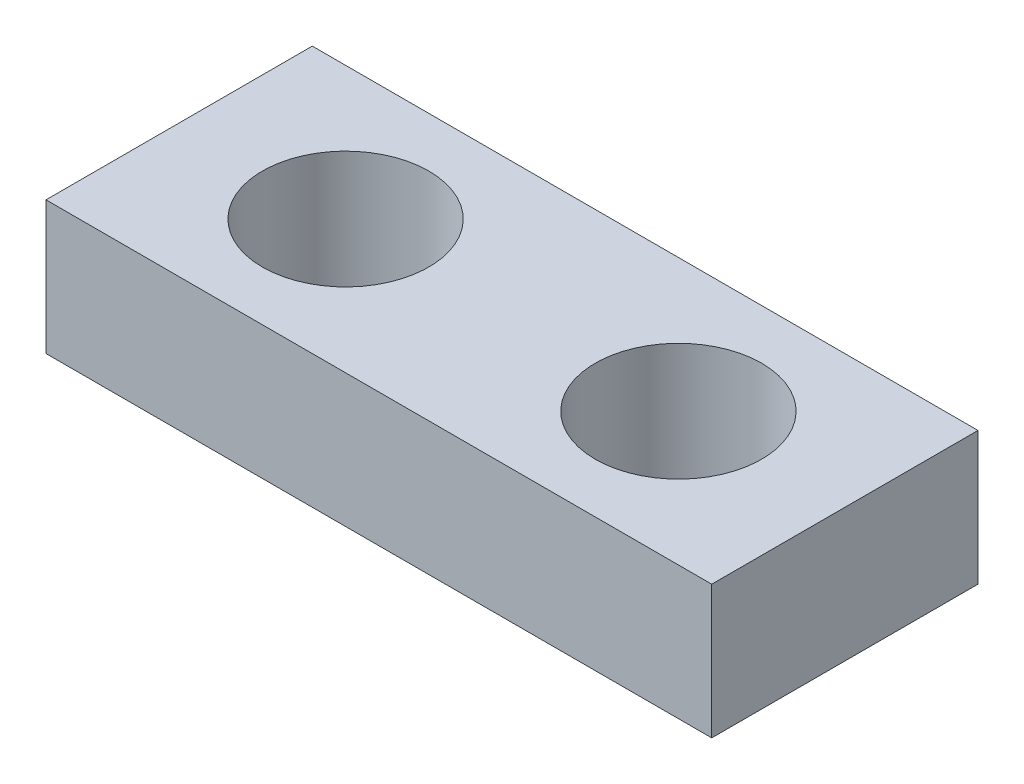
from build123d import *

# Parameters (mm, degrees)
SKETCH1_W           = 127
SKETCH1_H           = 50.8
BOSS_EXTRUDE1_DEPTH = 25.4
SKETCH2_R           = 15.875
CUT_EXTRUDE1_DEPTH  = 26.4


with BuildPart() as part:
    # Sketch1 → Boss-Extrude1 (new body)
    with BuildSketch(Plane(origin=(0, 0, 0), x_dir=(1, 0, 0), z_dir=(0, 1, 0))):
        with Locations((63.5, 25.4)):
            Rectangle(SKETCH1_W, SKETCH1_H)
    extrude(amount=BOSS_EXTRUDE1_DEPTH)

    # Sketch2 → Cut-Extrude1 (cut, through all)
    with BuildSketch(Plane(origin=(0, 25.4, 0), x_dir=(1, 0, 0), z_dir=(0, 1, 0))):
        with Locations((31.75, 25.4)):
            Circle(SKETCH2_R)
        with Locations((95.25, 25.4)):
            Circle(SKETCH2_R)
    extrude(amount=-CUT_EXTRUDE1_DEPTH, mode=Mode.SUBTRACT)


solid = part.part
